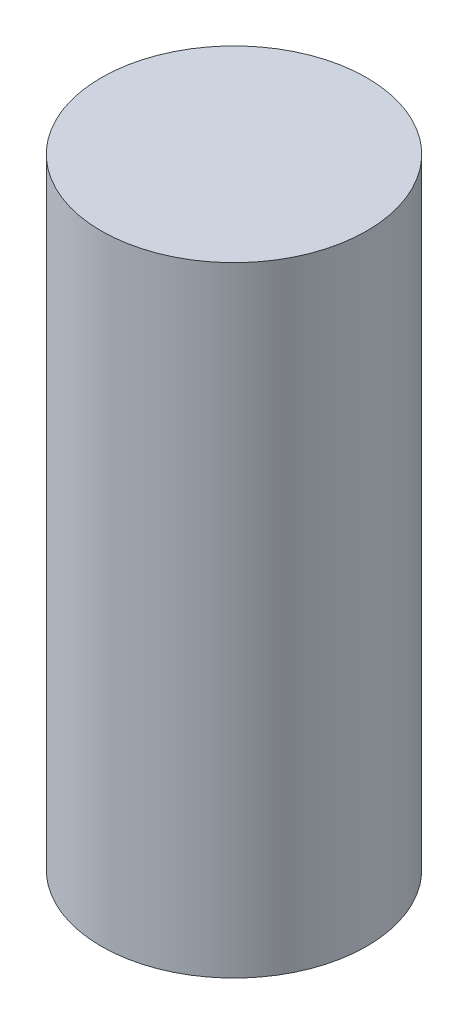
from build123d import *

# Parameters (mm, degrees)
SKETCH1_R           = 19.05
BOSS_EXTRUDE1_DEPTH = 88.9


with BuildPart() as part:
    # Sketch1 → Boss-Extrude1 (new body)
    with BuildSketch(Plane(origin=(0, 0, 0), x_dir=(1, 0, 0), z_dir=(0, 1, 0))):
        Circle(SKETCH1_R)
    extrude(amount=BOSS_EXTRUDE1_DEPTH)


solid = part.part
